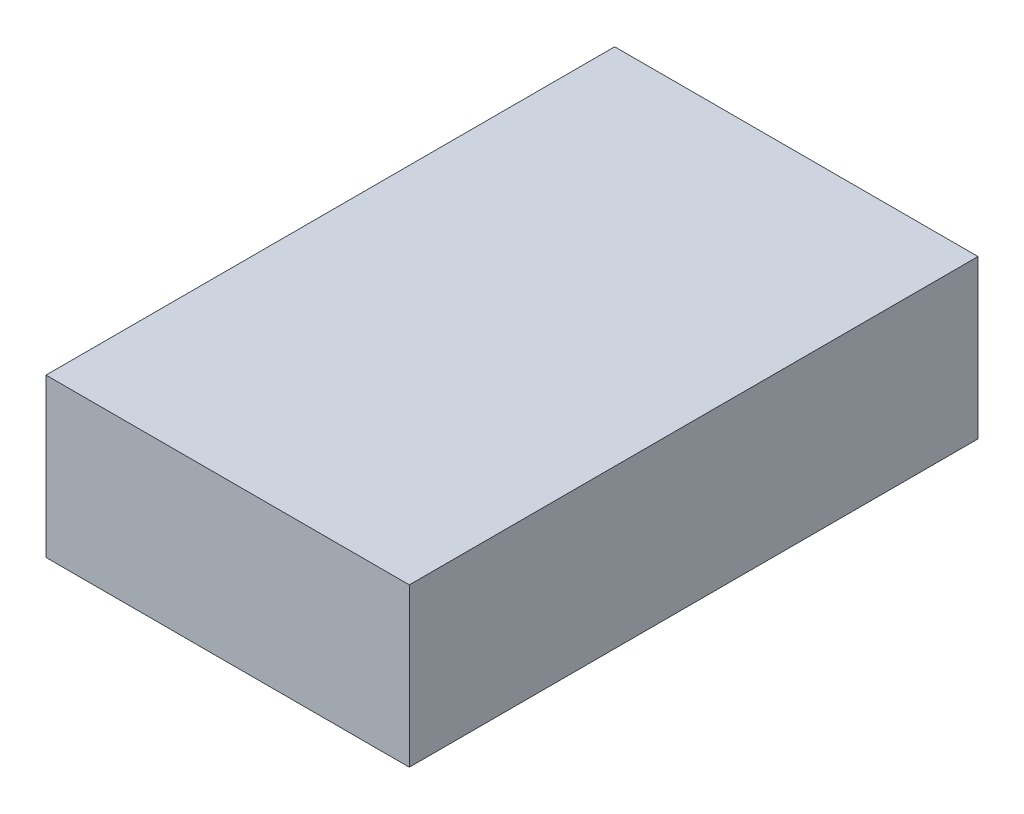
from build123d import *

# Parameters (mm, degrees)
SKETCH1_W           = 23
SKETCH1_H           = 36
BOSS_EXTRUDE1_DEPTH = 10


with BuildPart() as part:
    # Sketch1 → Boss-Extrude1 (new body)
    with BuildSketch(Plane(origin=(0, 0, 0), x_dir=(1, 0, 0), z_dir=(0, 1, 0))):
        with Locations((0.200348432, -16.116724739)):
            Rectangle(SKETCH1_W, SKETCH1_H)
    extrude(amount=BOSS_EXTRUDE1_DEPTH)


solid = part.part
